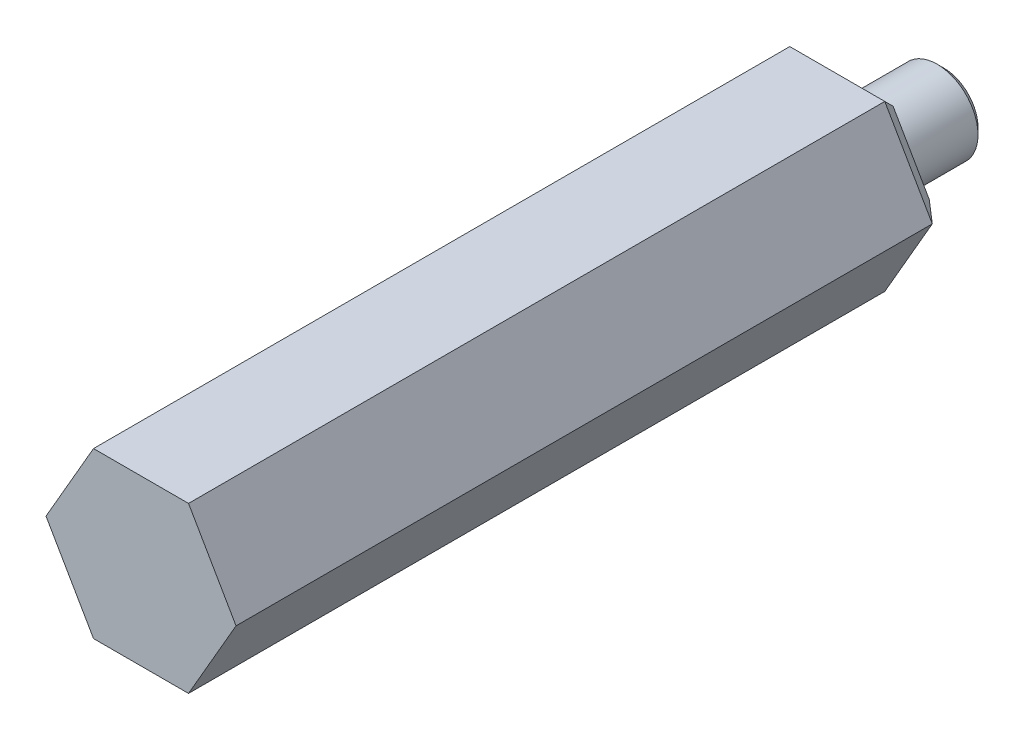
from build123d import *

# Parameters (mm, degrees)
CHAMFER1_SIZE  = 0.50801365
EXTRUDE1_REACH = 57.499
CHAMFER2_SIZE  = 1.524


with BuildPart() as part:
    # Sketch1 → Revolve1 (revolve)
    with BuildSketch(Plane(origin=(0, 0, 0), x_dir=(1, 0, 0), z_dir=(0, 1, 0)), mode=Mode.PRIVATE) as revolve1_sk:
        Polygon((7.366, -27.7495), (7.366, 27.7495), (3.1623, 27.7495), (3.1623, 34.4805), (0, 34.4805), (0, -27.7495), align=None)
    revolve(revolve1_sk.sketch.rotate(Axis((0, 0, -34.4805), (0, 0, 1)), 180), axis=Axis((0, 0, -34.4805), (0, 0, 1)))  # turned: the seam where the file's is

    # Chamfer1
    chamfer1_edges = [part.edges().sort_by_distance(p)[0] for p in [
        (3.1623, 0, -34.4805),
    ]]
    chamfer(chamfer1_edges, length=CHAMFER1_SIZE)

    # Sketch2 → Extrude1 (cut, up to next)
    with BuildSketch(Plane(origin=(0, 0, -27.7495), x_dir=(-1, 0, 0), z_dir=(0, 0, -1)), mode=Mode.PRIVATE) as extrude1_sk1:
        with BuildLine():
            ThreePointArc((3.683, 6.379143124), (0, 7.366), (-3.683, 6.379143124))
            Line((-3.683, 6.379143124), (3.683, 6.379143124))
        make_face()
    extrude1_tool1 = extrude(extrude1_sk1.sketch, amount=-EXTRUDE1_REACH, mode=Mode.PRIVATE) & part.part
    add(extrude1_tool1.solids().sort_by_distance((0, 6.776244, -27.7495))[0], mode=Mode.SUBTRACT)
    # Sketch2 → Extrude1 (cut, up to next)
    with BuildSketch(Plane(origin=(0, 0, -27.7495), x_dir=(-1, 0, 0), z_dir=(0, 0, -1)), mode=Mode.PRIVATE) as extrude1_sk2:
        with BuildLine():
            ThreePointArc((7.366, 0), (6.379143124, 3.683), (3.683, 6.379143124))
            Line((3.683, 6.379143124), (7.366, 0))
        make_face()
    extrude1_tool2 = extrude(extrude1_sk2.sketch, amount=-EXTRUDE1_REACH, mode=Mode.PRIVATE) & part.part
    add(extrude1_tool2.solids().sort_by_distance((-5.868399, 3.388122, -27.7495))[0], mode=Mode.SUBTRACT)
    # Sketch2 → Extrude1 (cut, up to next)
    with BuildSketch(Plane(origin=(0, 0, -27.7495), x_dir=(-1, 0, 0), z_dir=(0, 0, -1)), mode=Mode.PRIVATE) as extrude1_sk3:
        with BuildLine():
            Line((7.366, 0), (3.683, -6.379143124))
            ThreePointArc((3.683, -6.379143124), (6.379143124, -3.683), (7.366, 0))
        make_face()
    extrude1_tool3 = extrude(extrude1_sk3.sketch, amount=-EXTRUDE1_REACH, mode=Mode.PRIVATE) & part.part
    add(extrude1_tool3.solids().sort_by_distance((-5.868399, -3.388122, -27.7495))[0], mode=Mode.SUBTRACT)
    # Sketch2 → Extrude1 (cut, up to next)
    with BuildSketch(Plane(origin=(0, 0, -27.7495), x_dir=(-1, 0, 0), z_dir=(0, 0, -1)), mode=Mode.PRIVATE) as extrude1_sk4:
        with BuildLine():
            Line((3.683, -6.379143124), (-3.683, -6.379143124))
            ThreePointArc((-3.683, -6.379143124), (0, -7.366), (3.683, -6.379143124))
        make_face()
    extrude1_tool4 = extrude(extrude1_sk4.sketch, amount=-EXTRUDE1_REACH, mode=Mode.PRIVATE) & part.part
    add(extrude1_tool4.solids().sort_by_distance((0, -6.776244, -27.7495))[0], mode=Mode.SUBTRACT)
    # Sketch2 → Extrude1 (cut, up to next)
    with BuildSketch(Plane(origin=(0, 0, -27.7495), x_dir=(-1, 0, 0), z_dir=(0, 0, -1)), mode=Mode.PRIVATE) as extrude1_sk5:
        with BuildLine():
            Line((-3.683, -6.379143124), (-7.366, 0))
            ThreePointArc((-7.366, 0), (-6.379143124, -3.683), (-3.683, -6.379143124))
        make_face()
    extrude1_tool5 = extrude(extrude1_sk5.sketch, amount=-EXTRUDE1_REACH, mode=Mode.PRIVATE) & part.part
    add(extrude1_tool5.solids().sort_by_distance((5.868399, -3.388122, -27.7495))[0], mode=Mode.SUBTRACT)
    # Sketch2 → Extrude1 (cut, up to next)
    with BuildSketch(Plane(origin=(0, 0, -27.7495), x_dir=(-1, 0, 0), z_dir=(0, 0, -1)), mode=Mode.PRIVATE) as extrude1_sk6:
        with BuildLine():
            ThreePointArc((-3.683, 6.379143124), (-6.379143124, 3.683), (-7.366, 0))
            Line((-7.366, 0), (-3.683, 6.379143124))
        make_face()
    extrude1_tool6 = extrude(extrude1_sk6.sketch, amount=-EXTRUDE1_REACH, mode=Mode.PRIVATE) & part.part
    add(extrude1_tool6.solids().sort_by_distance((5.868399, 3.388122, -27.7495))[0], mode=Mode.SUBTRACT)

    # Chamfer2
    chamfer2_edges = [part.edges().sort_by_distance(p)[0] for p in [
        (0, 6.379143124, -27.7495),
        (-5.5245, 3.189571562, -27.7495),
        (-5.5245, -3.189571562, -27.7495),
        (0, -6.379143124, -27.7495),
        (5.5245, -3.189571562, -27.7495),
        (5.5245, 3.189571562, -27.7495),
    ]]
    chamfer(chamfer2_edges, length=CHAMFER2_SIZE)


solid = part.part
